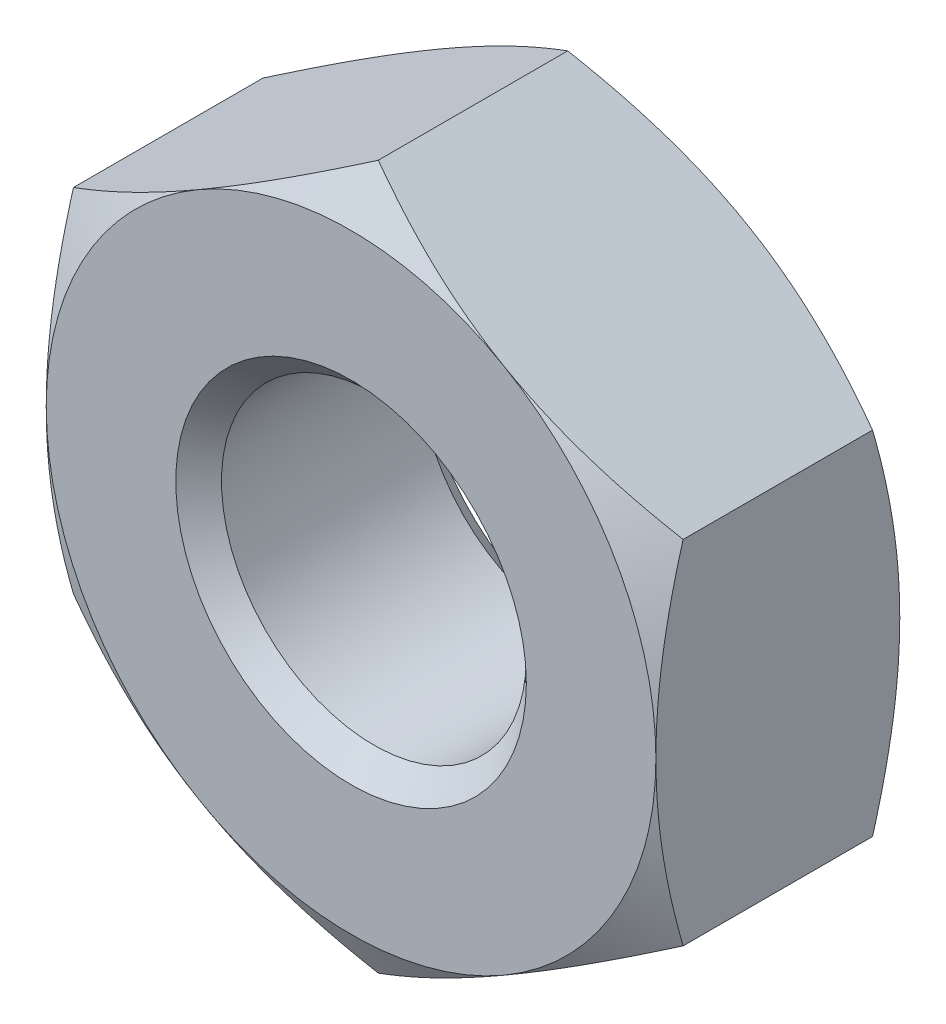
from build123d import *

# Parameters (mm, degrees)
SKETCH1_R           = 3
SKETCH1_R_2         = 1
BOSS_EXTRUDE1_DEPTH = 1.6
CHAMFER1_SIZE       = 1
CHAMFER1_SIZE2      = 0.577350269
CHAMFER2_SIZE       = 1
CHAMFER2_SIZE2      = 0.577350269
SKETCH1_3_R         = 3
CUT_EXTRUDE1_DEPTH  = 2.6
CHAMFER3_SIZE       = 0.15


with BuildPart() as part:
    # Sketch1 → Boss-Extrude1 (new body)
    with BuildSketch(Plane.XY):
        Circle(SKETCH1_R)
        Polygon((2, 1.154700538), (0, 2.309401077), (-2, 1.154700538), (-2, -1.154700538), (0, -2.309401077), (2, -1.154700538), align=None, mode=Mode.SUBTRACT)
        Polygon((2, -1.154700538), (2, 1.154700538), (0, 2.309401077), (-2, 1.154700538), (-2, -1.154700538), (0, -2.309401077), align=None)
        Circle(SKETCH1_R_2, mode=Mode.SUBTRACT)
    extrude(amount=BOSS_EXTRUDE1_DEPTH)

    # Chamfer1
    chamfer1_edges = [part.edges().sort_by_distance(p)[0] for p in [
        (-3, 0, 1.6),
    ]]
    chamfer1_side = [part.faces().sort_by_distance(p)[0] for p in [
        (-2.915147186, 0, 1.6),
    ]]
    chamfer(chamfer1_edges, length=CHAMFER1_SIZE, length2=CHAMFER1_SIZE2, reference=chamfer1_side[0])

    # Chamfer2
    chamfer2_edges = [part.edges().sort_by_distance(p)[0] for p in [
        (-3, 0, 0),
    ]]
    chamfer2_side = [part.faces().sort_by_distance(p)[0] for p in [
        (-2.915147186, 0, 0),
    ]]
    chamfer(chamfer2_edges, length=CHAMFER2_SIZE, length2=CHAMFER2_SIZE2, reference=chamfer2_side[0])

    # Sketch1_3 → Cut-Extrude1 (cut, through all)
    with BuildSketch(Plane.XY):
        Circle(SKETCH1_3_R)
        Polygon((2, 1.154700538), (0, 2.309401077), (-2, 1.154700538), (-2, -1.154700538), (0, -2.309401077), (2, -1.154700538), align=None, mode=Mode.SUBTRACT)
    extrude(amount=CUT_EXTRUDE1_DEPTH, mode=Mode.SUBTRACT)

    # Chamfer3
    chamfer3_edges = [part.edges().sort_by_distance(p)[0] for p in [
        (-1, 0, 0),
        (-1, 0, 1.6),
    ]]
    chamfer(chamfer3_edges, length=CHAMFER3_SIZE)


solid = part.part
